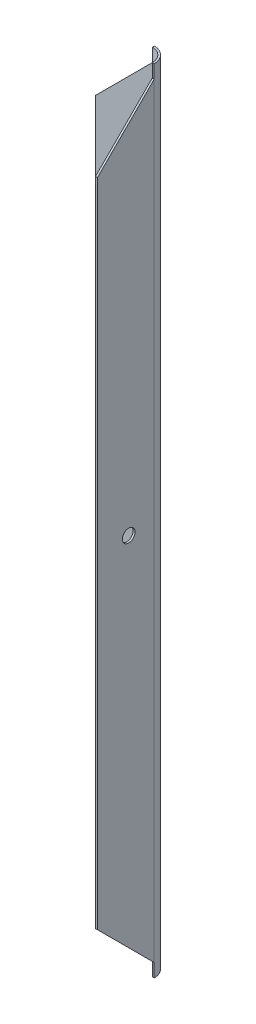
from build123d import *

# Parameters (mm, degrees)
BOSS_EXTRUDE1_DEPTH     = 1.5
BOSS_EXTRUDE3_DEPTH     = 1.5
CUT_EXTRUDE1_DEPTH      = 625.993799969
CUT_EXTRUDE1_DEPTH_BACK = 625.993799969
BOSS_EXTRUDE4_DEPTH     = 620
CUT_EXTRUDE2_DEPTH      = 321.132004023
CUT_EXTRUDE2_DEPTH_BACK = 321.132004023
SKETCH6_R               = 5
CUT_EXTRUDE3_DEPTH      = 320.870676993
CUT_EXTRUDE3_DEPTH_BACK = 320.870676993
SKETCH7_R               = 5


with BuildPart() as part:
    # Sketch1 → Boss-Extrude1 (new body)
    with BuildSketch(Plane(origin=(0, 0, 0), x_dir=(0, 0, -1), z_dir=(1, 0, 0))):
        Polygon((0, -255), (55, -310), (56.5, -310), (56.5, 310), (55, 310), (0, 255), align=None)
    extrude(amount=BOSS_EXTRUDE1_DEPTH)

    # Sketch2 → Boss-Extrude3 (add)
    with BuildSketch(Plane(origin=(0, 0, -56.5), x_dir=(-1, 0, 0), z_dir=(0, 0, -1))):
        Polygon((55, 255), (55, -255), (0, -310), (0, 310), align=None)
    extrude(amount=-BOSS_EXTRUDE3_DEPTH)

    # Sketch5 → Cut-Extrude1 (cut, two sides: drawn at the far end of the back side and taken through both)
    with BuildSketch(Plane.XZ.offset(310).offset(-CUT_EXTRUDE1_DEPTH_BACK)):
        with BuildLine():
            ThreePointArc((1.5, -44.5), (-2.014718626, -52.985281374), (-10.5, -56.5))
            Line((-10.5, -56.5), (1.5, -56.5))
            Line((1.5, -56.5), (1.5, -44.5))
        make_face()
    extrude(amount=CUT_EXTRUDE1_DEPTH + CUT_EXTRUDE1_DEPTH_BACK, mode=Mode.SUBTRACT)


with BuildPart() as cut_extrude1_piece_1:
    # of the separate pieces the step leaves, piece 1, a body of its own (cut_extrude1_pieces)
    add(part.part.solids().sort_by_distance((-4.690524981, 305.309475019, -55))[0])



with BuildPart() as cut_extrude1_piece_2:
    # of the separate pieces the step leaves, piece 2, a body of its own (cut_extrude1_pieces)
    add(part.part.solids().sort_by_distance((0, 255, 0))[0])


with BuildPart() as cut_extrude1_piece_1_1:
    add(cut_extrude1_piece_1.part)

    add(cut_extrude1_piece_2.part)  # Boss-Extrude4 merges Cut-Extrude1 piece 2
    # Sketch5_3 → Boss-Extrude4 (add)
    with BuildSketch(Plane.XZ.offset(310)):
        with BuildLine():
            ThreePointArc((0, -44.5), (-3.075378798, -51.924621202), (-10.5, -55))
            Line((-10.5, -55), (-10.5, -56.5))
            ThreePointArc((-10.5, -56.5), (-2.014718626, -52.985281374), (1.5, -44.5))
            Line((1.5, -44.5), (0, -44.5))
        make_face()
    extrude(amount=-BOSS_EXTRUDE4_DEPTH)

    # Sketch6 → Cut-Extrude2 (cut, two sides: drawn at the far end of the back side and taken through both)
    with BuildSketch(Plane(origin=(1.5, 0, 0), x_dir=(0, 0, -1), z_dir=(1, 0, 0)).offset(-CUT_EXTRUDE2_DEPTH_BACK)):
        with Locations((24.5, 0)):
            Circle(SKETCH6_R)
    extrude(amount=CUT_EXTRUDE2_DEPTH + CUT_EXTRUDE2_DEPTH_BACK, mode=Mode.SUBTRACT)

    # Sketch7 → Cut-Extrude3 (cut, two sides: drawn at the far end of the back side and taken through both)
    with BuildSketch(Plane(origin=(0, 0, -56.5), x_dir=(-1, 0, 0), z_dir=(0, 0, -1)).offset(-CUT_EXTRUDE3_DEPTH_BACK)):
        with Locations((30.5, 0)):
            Circle(SKETCH7_R)
    extrude(amount=CUT_EXTRUDE3_DEPTH + CUT_EXTRUDE3_DEPTH_BACK, mode=Mode.SUBTRACT)


solid = cut_extrude1_piece_1_1.part
